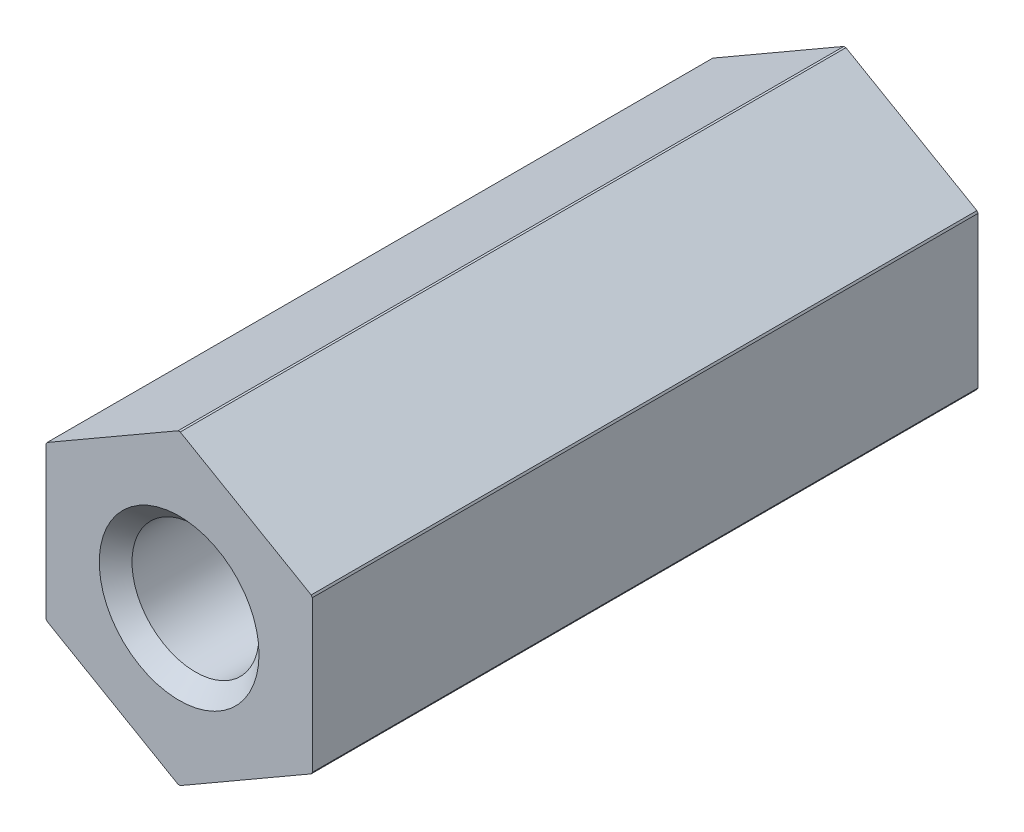
from build123d import *

# Parameters (mm, degrees)
SKETCH2_W          = 20
SKETCH2_H          = 20
CUT_EXTRUDE1_DEPTH = 25


with BuildPart() as part:
    # Sketch1 → Revolve1 (revolve)
    with BuildSketch(Plane(origin=(0, 0, 0), x_dir=(0, 0, -1), z_dir=(1, 0, 0))):
        Polygon((-25, 3), (-24.385665, 2.385665), (-1.317445659, 2.385665), (0, 3), (0, 5.75), (-25, 5.75), align=None)
    revolve(axis=Axis((0, 0, 0), (0, 0, 1)))

    # Sketch2 → Cut-Extrude1 (cut)
    with BuildSketch(Plane.XY):
        Rectangle(SKETCH2_W, SKETCH2_H)
        Polygon((-5, 2.886751346), (-5, -2.886751346), (0, -5.773502692), (5, -2.886751346), (5, 2.886751346), (0, 5.773502692), align=None, mode=Mode.SUBTRACT)
    extrude(amount=CUT_EXTRUDE1_DEPTH, mode=Mode.SUBTRACT)


solid = part.part
